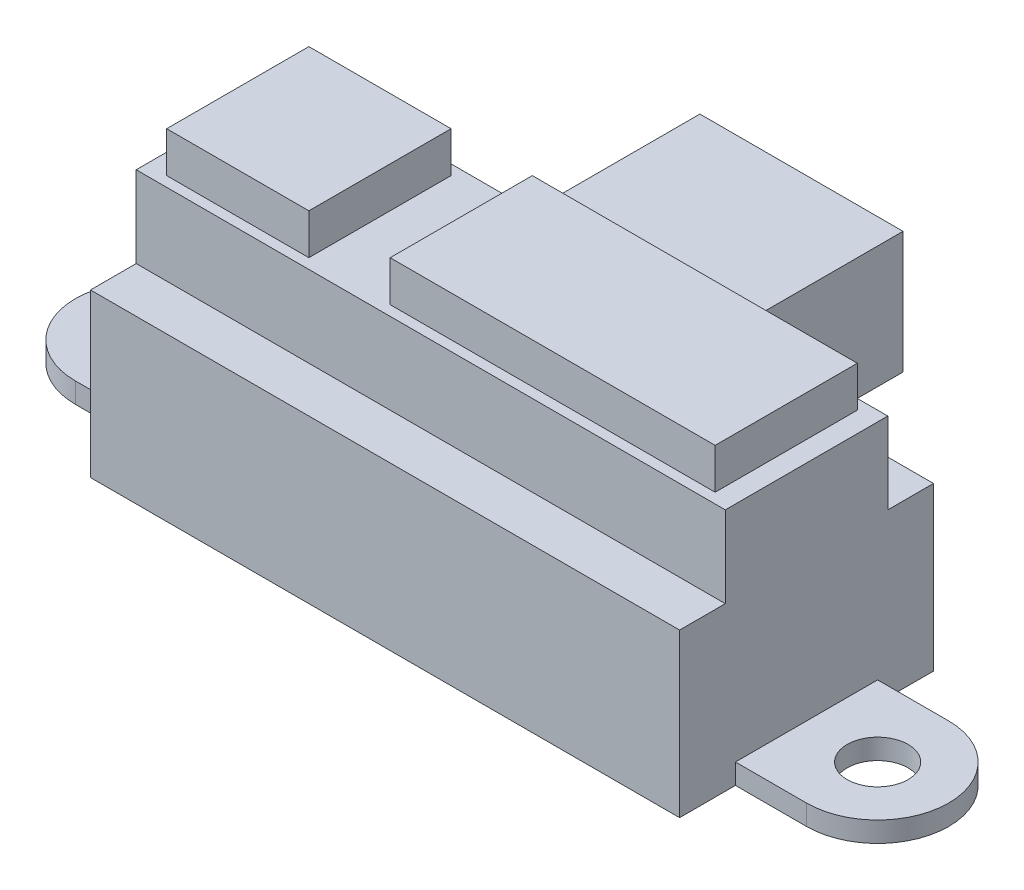
from build123d import *

# Parameters (mm, degrees)
SKETCH_1_R          = 1.5
EXTRUDE_1_DEPTH     = 1
SKETCH_3_W          = 29
SKETCH_3_H          = 12.5
EXTRUDE_2_DEPTH     = 14
SKETCH_4_W          = 10
SKETCH_4_H          = 6
EXTRUDE_3_DEPTH     = 8
SKETCH_5_W          = 29
SKETCH_5_H          = 2.25
CUT_EXTRUDE_1_DEPTH = 6
SKETCH_6_W          = 29
SKETCH_6_H          = 12.5
SKETCH_6_W_2        = 27
SKETCH_6_H_2        = 7
CUT_EXTRUDE_2_DEPTH = 2
SKETCH_7_W          = 4
SKETCH_7_H          = 7
CUT_EXTRUDE_3_DEPTH = 2


with BuildPart() as part:
    # 草图1 → 凸台-拉伸1 (new body)
    with BuildSketch(Plane(origin=(0, 0, 0), x_dir=(1, 0, 0), z_dir=(0, 1, 0))):
        with BuildLine():
            Line((-18, -3.5), (18, -3.5))
            ThreePointArc((18, -3.5), (21.5, 0), (18, 3.5))
            Line((18, 3.5), (-18, 3.5))
            ThreePointArc((-18, 3.5), (-21.5, 0), (-18, -3.5))
        make_face()
        with Locations((-18, 0)):
            Circle(SKETCH_1_R, mode=Mode.SUBTRACT)
        with Locations((18, 0)):
            Circle(SKETCH_1_R, mode=Mode.SUBTRACT)
    extrude(amount=EXTRUDE_1_DEPTH)

    # 草图3 → 凸台-拉伸2 (add)
    with BuildSketch(Plane.XZ):
        Rectangle(SKETCH_3_W, SKETCH_3_H)
    extrude(amount=-EXTRUDE_2_DEPTH)

    # 草图4 → 凸台-拉伸3 (add)
    with BuildSketch(Plane(origin=(0, 0, -6.25), x_dir=(-1, 0, 0), z_dir=(0, 0, -1))):
        with Locations((0, 7)):
            Rectangle(SKETCH_4_W, SKETCH_4_H)
    extrude(amount=EXTRUDE_3_DEPTH)

    # 草图5 → 切除-拉伸1 (cut)
    with BuildSketch(Plane(origin=(0, 14, 0), x_dir=(1, 0, 0), z_dir=(0, 1, 0))):
        with Locations((0, 5.125)):
            Rectangle(SKETCH_5_W, SKETCH_5_H)
        with Locations((0, -5.125)):
            Rectangle(SKETCH_5_W, SKETCH_5_H)
    extrude(amount=-CUT_EXTRUDE_1_DEPTH, mode=Mode.SUBTRACT)

    # 草图6 → 切除-拉伸2 (cut)
    with BuildSketch(Plane(origin=(0, 14, 0), x_dir=(1, 0, 0), z_dir=(0, 1, 0))):
        Rectangle(SKETCH_6_W, SKETCH_6_H)
        Rectangle(SKETCH_6_W_2, SKETCH_6_H_2, mode=Mode.SUBTRACT)
    extrude(amount=-CUT_EXTRUDE_2_DEPTH, mode=Mode.SUBTRACT)

    # 草图7 → 切除-拉伸3 (cut)
    with BuildSketch(Plane(origin=(0, 14, 0), x_dir=(1, 0, 0), z_dir=(0, 1, 0))):
        with Locations((-4.5, 0)):
            Rectangle(SKETCH_7_W, SKETCH_7_H)
    extrude(amount=-CUT_EXTRUDE_3_DEPTH, mode=Mode.SUBTRACT)


solid = part.part
